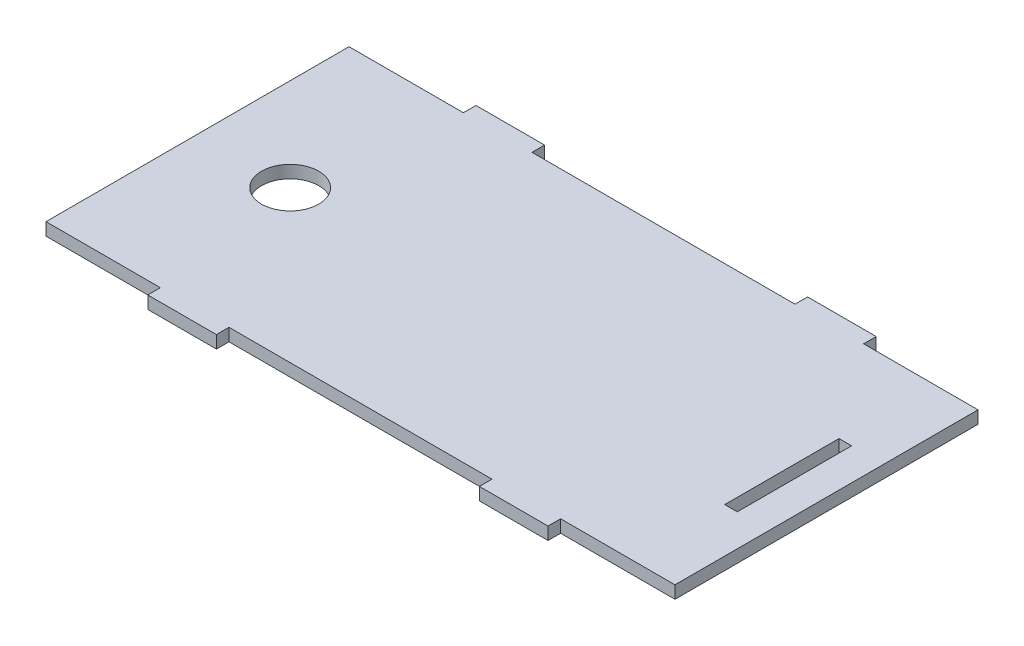
from build123d import *

# Parameters (mm, degrees)
SKETCH2_R           = 6.35
SKETCH2_W           = 2.794
SKETCH2_H           = 25.4
BOSS_EXTRUDE1_DEPTH = 2.794


with BuildPart() as part:
    # Sketch2 → Boss-Extrude1 (new body)
    with BuildSketch(Plane(origin=(0, 0, 0), x_dir=(1, 0, 0), z_dir=(0, 1, 0))):
        Polygon((0, 0), (25.4, 0), (25.4, -2.794), (40.64, -2.794), (40.64, 0), (99.06, 0), (99.06, -2.794), (114.3, -2.794), (114.3, 0), (139.7, 0), (139.7, 67.31), (114.3, 67.31), (114.3, 70.104), (99.06, 70.104), (99.06, 67.31), (40.64, 67.31), (40.64, 70.104), (25.4, 70.104), (25.4, 67.31), (0, 67.31), align=None)
        with Locations((20.574, 33.655)):
            Circle(SKETCH2_R, mode=Mode.SUBTRACT)
        with Locations((131.191, 33.655)):
            Rectangle(SKETCH2_W, SKETCH2_H, mode=Mode.SUBTRACT)
    extrude(amount=BOSS_EXTRUDE1_DEPTH)


solid = part.part
